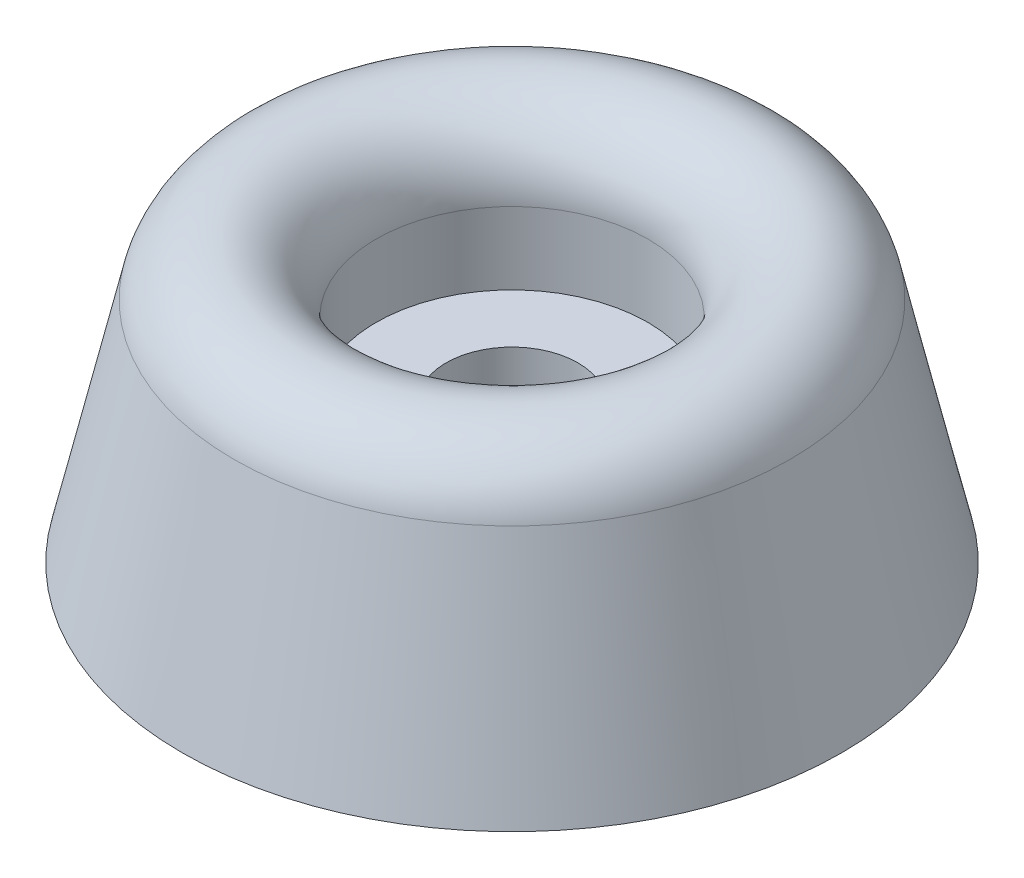
from build123d import *


with BuildPart() as part:
    # Sketch1 → Revolve1 (revolve)
    with BuildSketch(Plane.XY):
        with BuildLine():
            Line((10.435817327, 8.567228799), (12.3825, 0))
            Line((12.3825, 0), (2.4765, 0))
            Line((2.4765, 0), (2.4765, 5.2578))
            Line((2.4765, 5.2578), (5.1054, 5.2578))
            Line((5.1054, 5.2578), (5.1054, 7.96925))
            ThreePointArc((5.1054, 7.96925), (7.50328511, 10.651176897), (10.435817327, 8.567228799))
        make_face()
    revolve(axis=Axis((0, 0, 0), (0, 1, 0)))


solid = part.part
